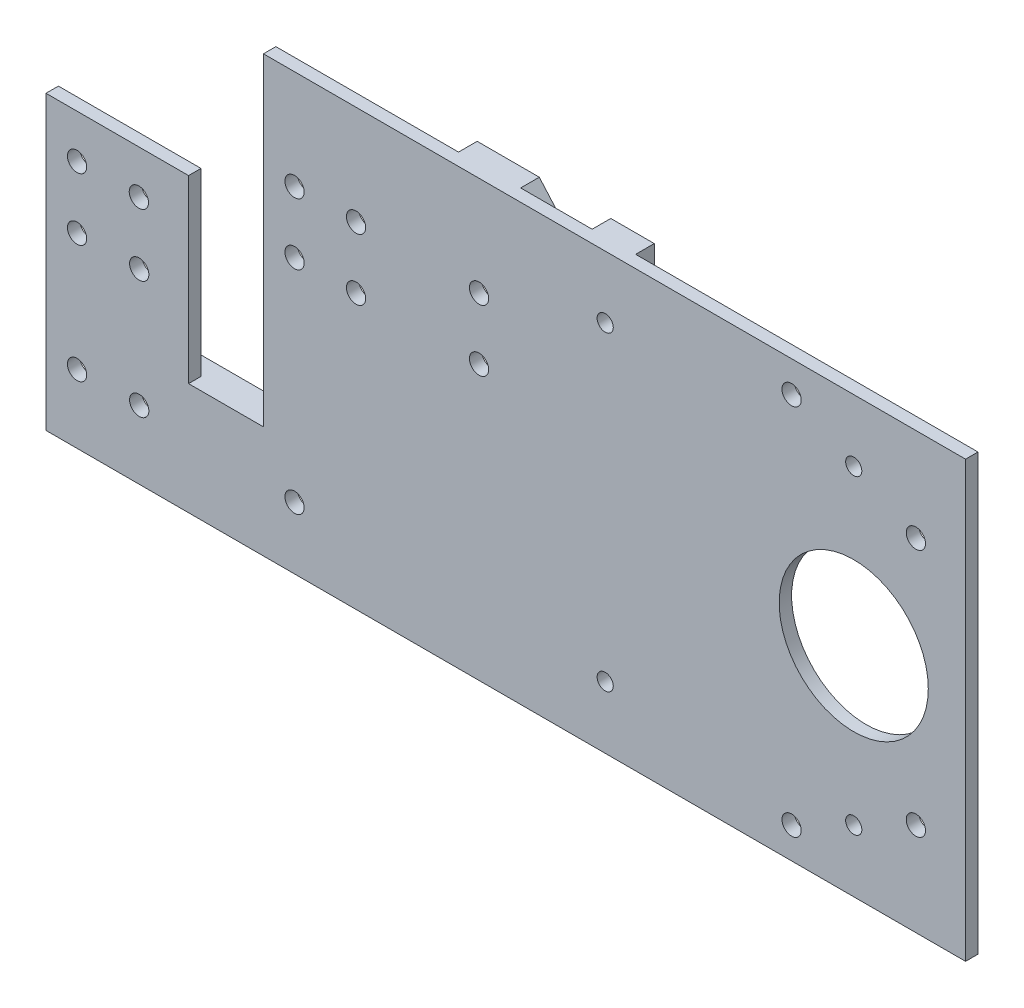
from build123d import *

# Parameters (mm, degrees)
SKETCH_1_R      = 1.55
SKETCH_1_R_2    = 1.3
SKETCH_1_R_3    = 12
EXTRUDE_1_DEPTH = 2
SKETCH_2_W      = 5.700941524
SKETCH_2_H      = 9
SKETCH_2_R      = 1.3
EXTRUDE_2_DEPTH = 3


with BuildPart() as part:
    # 草图1 → 凸台-拉伸1 (new body)
    with BuildSketch(Plane.XY):
        Polygon((118, -35), (118, 35), (5, 35), (5, 19), (5, -17), (-7.054941738, -17), (-7.054941738, 4.999698131), (-7.054941738, 11.999849066), (-30, 11.999849066), (-30, -35), (-7.054941738, -35), (17.9, -35), align=None)
        with Locations((-25, -24)):
            Circle(SKETCH_1_R, mode=Mode.SUBTRACT)
        with Locations((-15, -24)):
            Circle(SKETCH_1_R, mode=Mode.SUBTRACT)
        with Locations((10, -25)):
            Circle(SKETCH_1_R, mode=Mode.SUBTRACT)
        with Locations((-25, -5)):
            Circle(SKETCH_1_R, mode=Mode.SUBTRACT)
        with Locations((-15, -5)):
            Circle(SKETCH_1_R, mode=Mode.SUBTRACT)
        with Locations((60, -25)):
            Circle(SKETCH_1_R_2, mode=Mode.SUBTRACT)
        with Locations((90, -30)):
            Circle(SKETCH_1_R, mode=Mode.SUBTRACT)
        with Locations((100, -25)):
            Circle(SKETCH_1_R_2, mode=Mode.SUBTRACT)
        with Locations((110, -20)):
            Circle(SKETCH_1_R, mode=Mode.SUBTRACT)
        with Locations((-25, 5)):
            Circle(SKETCH_1_R, mode=Mode.SUBTRACT)
        with Locations((-15.054941738, 4.999698131)):
            Circle(SKETCH_1_R, mode=Mode.SUBTRACT)
        with Locations((10, 9.1)):
            Circle(SKETCH_1_R, mode=Mode.SUBTRACT)
        with Locations((19.9, 9.1)):
            Circle(SKETCH_1_R, mode=Mode.SUBTRACT)
        with Locations((39.7, 9.1)):
            Circle(SKETCH_1_R, mode=Mode.SUBTRACT)
        with Locations((10, 19)):
            Circle(SKETCH_1_R, mode=Mode.SUBTRACT)
        with Locations((19.9, 19)):
            Circle(SKETCH_1_R, mode=Mode.SUBTRACT)
        with Locations((39.7, 19)):
            Circle(SKETCH_1_R, mode=Mode.SUBTRACT)
        with Locations((100, 0)):
            Circle(SKETCH_1_R_3, mode=Mode.SUBTRACT)
        with Locations((60, 25)):
            Circle(SKETCH_1_R_2, mode=Mode.SUBTRACT)
        with Locations((110, 20)):
            Circle(SKETCH_1_R, mode=Mode.SUBTRACT)
        with Locations((100, 25)):
            Circle(SKETCH_1_R_2, mode=Mode.SUBTRACT)
        with Locations((90, 30)):
            Circle(SKETCH_1_R, mode=Mode.SUBTRACT)
    extrude(amount=EXTRUDE_1_DEPTH)

    # 草图2 → 凸台-拉伸2 (add)
    with BuildSketch(Plane(origin=(0, 0, 0), x_dir=(-1, 0, 0), z_dir=(0, 0, -1))):
        Polygon((-62.898115349, 2.499732073), (-57.197173825, 9), (-34.39434765, 35), (-44.39434765, 35), (-55.898115349, 21.883294295), (-57.635924693, 19.901827498), (-62.898115349, 13.901827498), (-90, -17), (-80, -17), align=None)
        Polygon((30, -21), (30, -17), (7.054941738, -17), (-5, -17), (-57.197173825, -17), (-62.898115349, -17), (-80, -17), (-90, -17), (-90, -21), (-62.898115349, -21), (-57.197173825, -21), align=None)
        Polygon((30, -35), (30, -30), (-57.197173825, -30), (-62.898115349, -30), (-80, -30), (-80, -35), align=None)
        Polygon((-101.707321844, 13.901827498), (-62.898115349, 13.901827498), (-57.635924693, 19.901827498), (-62.898115349, 19.901827498), (-101.707321844, 19.901827498), align=None)
        with Locations((-60.047644587, -25.5)):
            Rectangle(SKETCH_2_W, SKETCH_2_H)
        with Locations((-60, -25)):
            Circle(SKETCH_2_R, mode=Mode.SUBTRACT)
        Polygon((-62.898115349, -17), (-57.197173825, -17), (-57.197173825, 9), (-62.898115349, 2.499732073), align=None)
        Polygon((-57.635924693, 19.901827498), (-55.898115349, 21.883294295), (-55.898115349, 35), (-62.898115349, 35), (-62.898115349, 19.901827498), align=None)
        with Locations((-60, 25)):
            Circle(SKETCH_2_R, mode=Mode.SUBTRACT)
    extrude(amount=EXTRUDE_2_DEPTH)


solid = part.part
